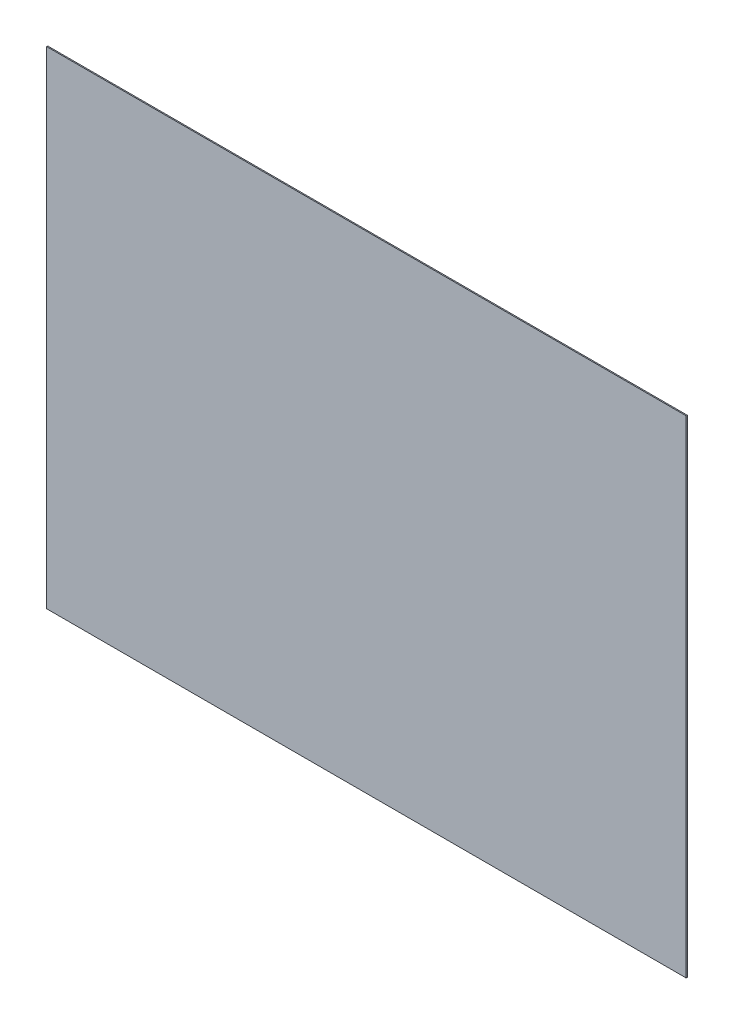
from build123d import *

# Parameters (mm, degrees)
SKETCH1_W           = 591
SKETCH1_H           = 450
BOSS_EXTRUDE1_DEPTH = 1


with BuildPart() as part:
    # Sketch1 → Boss-Extrude1 (new body)
    with BuildSketch(Plane.XY):
        Rectangle(SKETCH1_W, SKETCH1_H)
    extrude(amount=BOSS_EXTRUDE1_DEPTH)


solid = part.part
